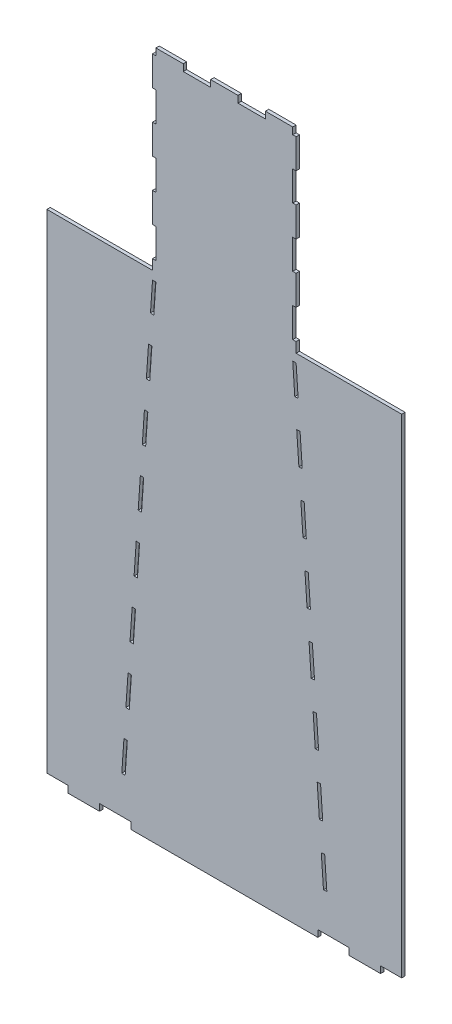
from build123d import *

# Parameters (mm, degrees)
BOSS_EXTRUDE1_DEPTH = 10.16
SKETCH5_W           = 63.5
SKETCH5_H           = 20.32
CUT_EXTRUDE1_DEPTH  = 11.16


with BuildPart() as part:
    # Sketch1 → Boss-Extrude1 (new body)
    with BuildSketch(Plane.XY):
        Polygon((-123.444, 2072.64), (-205.715298803, 2072.64), (-205.715298803, 2052.32), (-215.881789204, 2052.32), (-215.881789204, 1963.42), (-205.715298803, 1963.42), (-205.715298803, 1874.52), (-215.881789204, 1874.52), (-215.881789204, 1785.62), (-205.715298803, 1785.62), (-205.715298803, 1696.72), (-215.875298803, 1696.72), (-215.875298803, 1607.82), (-205.715298803, 1607.82), (-205.715298803, 1518.92), (-215.881789204, 1518.92), (-215.881789204, 1488.440000035), (-533.381789204, 1488.440000035), (-533.381789204, 0), (-375.428294602, 0), (-375.428294602, 20.32), (-280.9748, 20.32), (-280.9748, 0), (280.9748, 0), (280.9748, 20.32), (375.428294602, 20.32), (375.428294602, 0), (533.381789204, 0), (533.381789204, 1488.440000035), (215.881789204, 1488.440000035), (215.881789204, 1518.92), (205.715298803, 1518.92), (205.715298803, 1607.82), (215.875298803, 1607.82), (215.875298803, 1696.72), (205.715298803, 1696.72), (205.715298803, 1785.62), (215.881789204, 1785.62), (215.881789204, 1874.52), (205.715298803, 1874.52), (205.715298803, 1963.42), (215.881789204, 1963.42), (215.881789204, 2052.32), (205.715298803, 2052.32), (205.715298803, 2072.64), (123.444, 2072.64), (123.444, 2052.32), (41.135649402, 2052.32), (41.135649402, 2072.64), (-41.135649402, 2072.64), (-41.135649402, 2052.32), (-123.444, 2052.32), align=None)
        Polygon((215.881789204, 1463.040000035), (222.040744894, 1374.366931824), (211.92306481, 1373.664189215), (205.715298803, 1463.040000035), align=None, mode=Mode.SUBTRACT)
        Polygon((-205.715298803, 1463.040000035), (-211.92306481, 1373.664189215), (-222.040744894, 1374.366931824), (-215.881789204, 1463.040000035), align=None, mode=Mode.SUBTRACT)
        Polygon((227.836927701, 1290.916856945), (234.358656272, 1197.020795404), (224.240976188, 1196.318052795), (217.719247617, 1290.214114336), align=None, mode=Mode.SUBTRACT)
        Polygon((-308.266124544, 132.94397688), (-301.755453134, 226.680843836), (-291.63777305, 225.978101227), (-298.14844446, 132.241234271), align=None, mode=Mode.SUBTRACT)
        Polygon((-289.435698895, 404.053512688), (-279.318018811, 403.350770078), (-285.830533081, 309.587370692), (-295.948213166, 310.290113301), align=None, mode=Mode.SUBTRACT)
        Polygon((-283.630301787, 487.636249721), (-277.115944656, 581.426181539), (-266.998264572, 580.72343893), (-273.512621703, 486.933507112), align=None, mode=Mode.SUBTRACT)
        Polygon((-264.796190418, 758.798850391), (-254.678510334, 758.096107781), (-261.194710324, 664.279643533), (-271.312390408, 664.982386142), align=None, mode=Mode.SUBTRACT)
        Polygon((-252.476436179, 936.171519242), (-242.358756095, 935.468776633), (-248.876798945, 841.625779953), (-258.99447903, 842.328522563), align=None, mode=Mode.SUBTRACT)
        Polygon((301.755453134, 226.680843836), (308.266124544, 132.94397688), (298.14844446, 132.241234271), (291.63777305, 225.978101227), align=None, mode=Mode.SUBTRACT)
        Polygon((279.318018811, 403.350770078), (289.435698895, 404.053512688), (295.948213166, 310.290113301), (285.830533081, 309.587370692), align=None, mode=Mode.SUBTRACT)
        Polygon((254.678510334, 758.096107781), (264.796190418, 758.798850391), (271.312390408, 664.982386142), (261.194710324, 664.279643533), align=None, mode=Mode.SUBTRACT)
        Polygon((242.358756095, 935.468776633), (252.476436179, 936.171519242), (258.99447903, 842.328522563), (248.876798945, 841.625779953), align=None, mode=Mode.SUBTRACT)
        Polygon((277.115944656, 581.426181539), (283.630301787, 487.636249721), (273.512621703, 486.933507112), (266.998264572, 580.72343893), align=None, mode=Mode.SUBTRACT)
        Polygon((-240.15668194, 1113.544188093), (-230.039001856, 1112.841445484), (-236.558887567, 1018.971916374), (-246.676567651, 1019.674658983), align=None, mode=Mode.SUBTRACT)
        Polygon((-227.836927701, 1290.916856945), (-217.719247617, 1290.214114336), (-224.240976188, 1196.318052795), (-234.358656272, 1197.020795404), align=None, mode=Mode.SUBTRACT)
        Polygon((230.039001856, 1112.841445484), (240.15668194, 1113.544188093), (246.676567651, 1019.674658983), (236.558887567, 1018.971916374), align=None, mode=Mode.SUBTRACT)
    extrude(amount=BOSS_EXTRUDE1_DEPTH)

    # Sketch5 → Cut-Extrude1 (cut, through all)
    with BuildSketch(Plane.XY.offset(10.16)):
        with Locations((-501.631789204, 10.16)):
            Rectangle(SKETCH5_W, SKETCH5_H)
        with Locations((501.631789204, 10.16)):
            Rectangle(SKETCH5_W, SKETCH5_H)
    extrude(amount=-CUT_EXTRUDE1_DEPTH, mode=Mode.SUBTRACT)


solid = part.part
